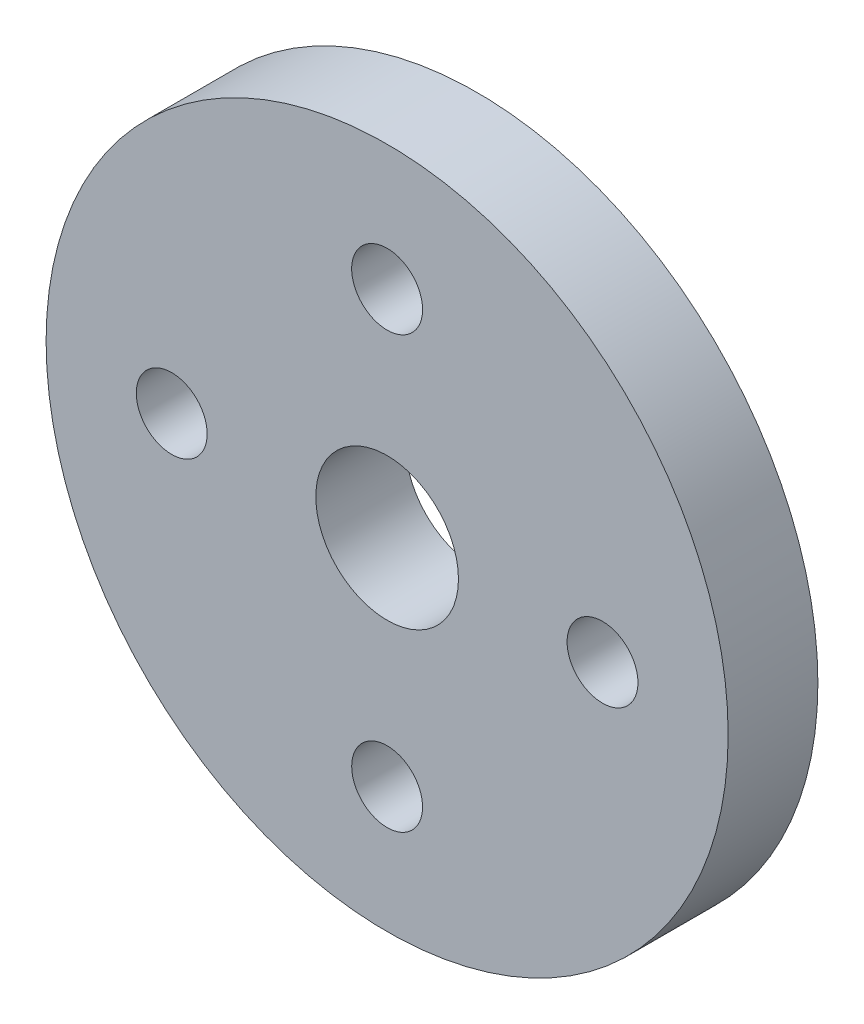
from build123d import *

# Parameters (mm, degrees)
SKETCH1_R           = 19
SKETCH1_R_2         = 1.975
SKETCH1_R_3         = 3.975
BOSS_EXTRUDE1_DEPTH = 5


with BuildPart() as part:
    # Sketch1 → Boss-Extrude1 (new body)
    with BuildSketch(Plane.XY):
        Circle(SKETCH1_R)
        with Locations((0, 12)):
            Circle(SKETCH1_R_2, mode=Mode.SUBTRACT)
        with Locations((0, -12)):
            Circle(SKETCH1_R_2, mode=Mode.SUBTRACT)
        with Locations((12, 0)):
            Circle(SKETCH1_R_2, mode=Mode.SUBTRACT)
        with Locations((-12, 0)):
            Circle(SKETCH1_R_2, mode=Mode.SUBTRACT)
        Circle(SKETCH1_R_3, mode=Mode.SUBTRACT)
    extrude(amount=BOSS_EXTRUDE1_DEPTH)


solid = part.part
